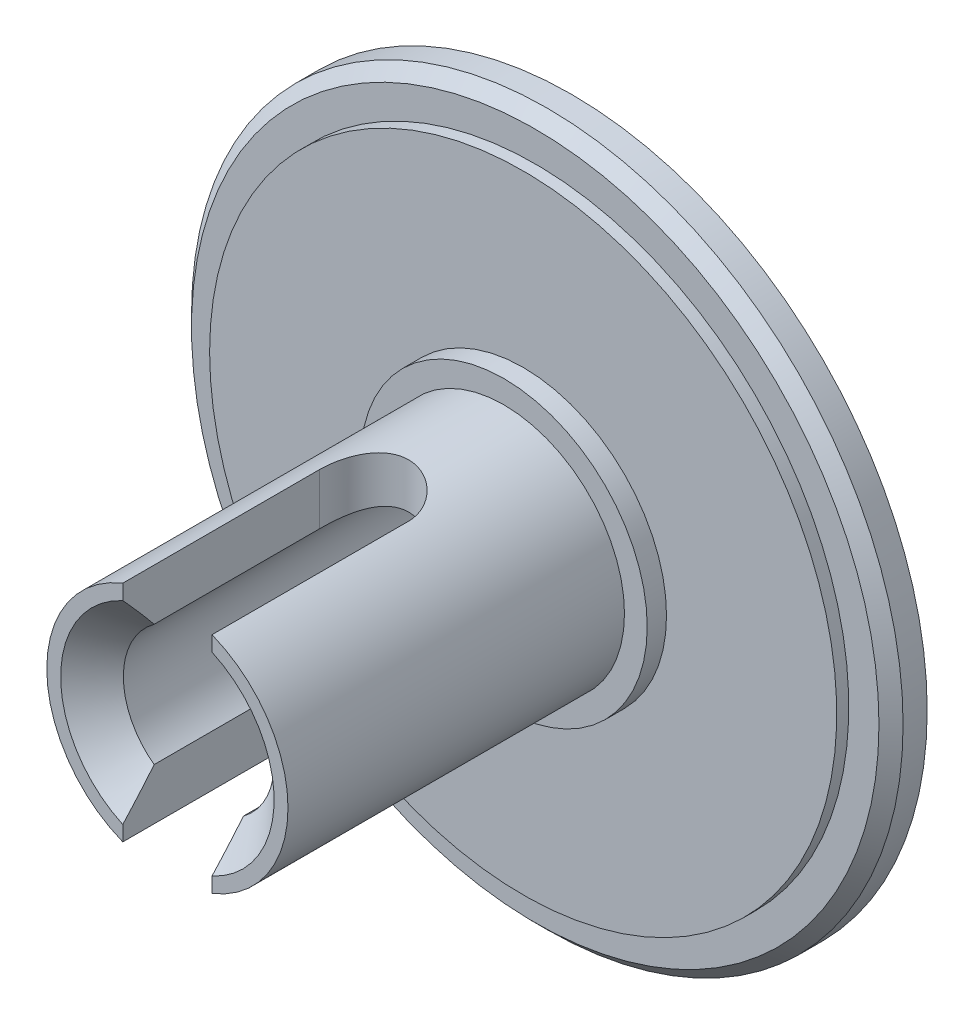
from build123d import *

# Parameters (mm, degrees)
FASE1_SIZE                           = 0.5
FASE2_SIZE                           = 1.3
SCHNITT_LINEAR_AUSTRAGEN1_DEPTH      = 15.75
SCHNITT_LINEAR_AUSTRAGEN1_DEPTH_BACK = 15.75
SKIZZE4_OUTSIDE_W                    = 40.932
SKIZZE4_OUTSIDE_H                    = 40.932
SKIZZE4_OUTSIDE_W_2                  = 20
SKIZZE4_OUTSIDE_H_2                  = 17
SCHNITT_LINEAR_AUSTRAGEN2_DEPTH      = 0.5


with BuildPart() as part:
    # Skizze2 → Rotation1 (revolve)
    with BuildSketch(Plane(origin=(0, 0, 0), x_dir=(0, 0, -1), z_dir=(1, 0, 0))):
        Polygon((0, 14.75), (-1.5, 14.75), (-1.5, 13), (-2, 13), (-2, 5.942548531), (-2.8, 5.942548531), (-2.8, 5), (-16.75, 5), (-16.75, 3.125), (-2.65, 3.125), (-2.65, 0.9), (5.25, 0.9), (5.25, 2.5), (0, 2.5), (0, 7.5), (0.5, 7.5), (0.5, 9.5), (0, 9.5), (0, 12.65), (-0.8, 12.65), (-0.8, 14.15), (0, 14.15), align=None)
    revolve(axis=Axis((0, 0, -10.606367747), (0, 0, 1)))

    # Fase1
    fase1_edges = [part.edges().sort_by_distance(p)[0] for p in [
        (0, -14.75, 1.5),
    ]]
    chamfer(fase1_edges, length=FASE1_SIZE)

    # Fase2
    fase2_edges = [part.edges().sort_by_distance(p)[0] for p in [
        (0, -3.125, 16.75),
    ]]
    chamfer(fase2_edges, length=FASE2_SIZE)

    # Skizze3 → Schnitt-Linear austragen1 (cut, two sides)
    with BuildSketch(Plane(origin=(0, 0, 0), x_dir=(1, 0, 0), z_dir=(0, 1, 0))) as schnitt_linear_austragen1_sk:
        with BuildLine():
            Line((1.85, -8.6), (1.85, -16.75))
            ThreePointArc((1.85, -16.75), (0, -18.6), (-1.85, -16.75))
            Line((-1.85, -16.75), (-1.85, -8.6))
            ThreePointArc((-1.85, -8.6), (0, -6.75), (1.85, -8.6))
        make_face()
    extrude(amount=SCHNITT_LINEAR_AUSTRAGEN1_DEPTH, mode=Mode.SUBTRACT)
    extrude(schnitt_linear_austragen1_sk.sketch, amount=-SCHNITT_LINEAR_AUSTRAGEN1_DEPTH_BACK, mode=Mode.SUBTRACT)

    # Skizze4 outside → Schnitt-Linear austragen2 (cut)
    with BuildSketch(Plane(origin=(0, 0, -0.5), x_dir=(-1, 0, 0), z_dir=(0, 0, -1))):
        Rectangle(SKIZZE4_OUTSIDE_W, SKIZZE4_OUTSIDE_H)
        Rectangle(SKIZZE4_OUTSIDE_W_2, SKIZZE4_OUTSIDE_H_2, mode=Mode.SUBTRACT)
    extrude(amount=-SCHNITT_LINEAR_AUSTRAGEN2_DEPTH, mode=Mode.SUBTRACT)


solid = part.part
